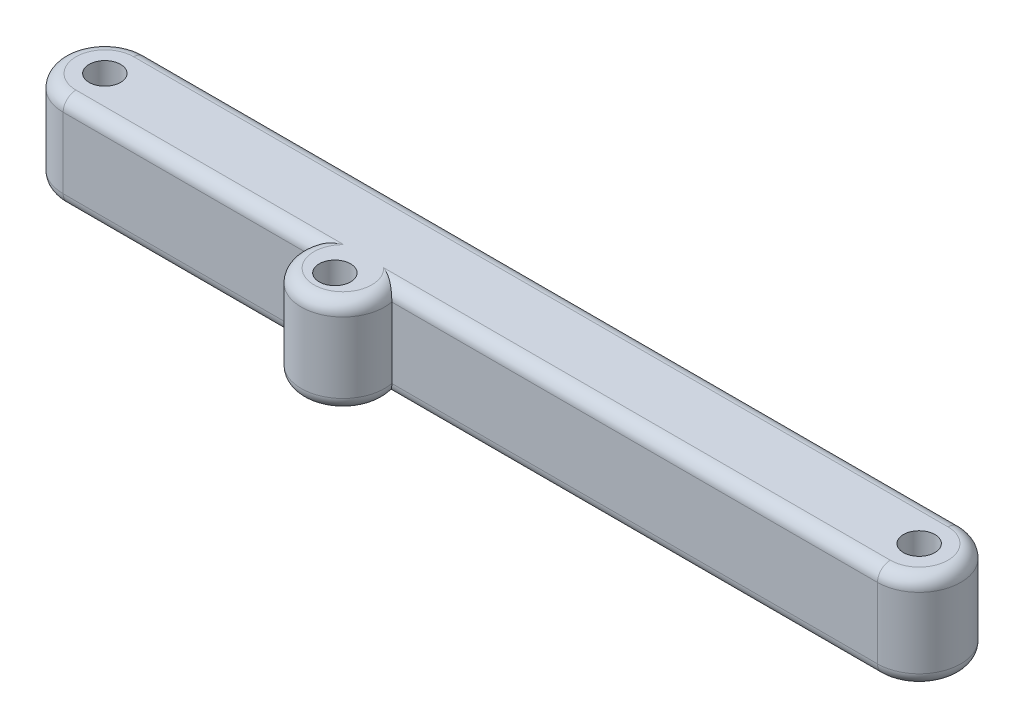
from build123d import *

# Parameters (mm, degrees)
SKETCH1_R           = 3.1115
BOSS_EXTRUDE1_DEPTH = 19.05
SKETCH2_R           = 8.255
SKETCH2_R_2         = 3.1115
BOSS_EXTRUDE2_DEPTH = 19.05
FILLET1_R           = 2.54


with BuildPart() as part:
    # Sketch1 → Boss-Extrude1 (new body)
    with BuildSketch(Plane(origin=(0, 0, 0), x_dir=(1, 0, 0), z_dir=(0, 1, 0))):
        with BuildLine():
            Line((-80.645, -8.255), (80.645, -8.255))
            ThreePointArc((80.645, -8.255), (88.9, 0), (80.645, 8.255))
            Line((80.645, 8.255), (-80.645, 8.255))
            ThreePointArc((-80.645, 8.255), (-88.9, 0), (-80.645, -8.255))
        make_face()
        with Locations((-80.645, 0)):
            Circle(SKETCH1_R, mode=Mode.SUBTRACT)
        with Locations((80.645, 0)):
            Circle(SKETCH1_R, mode=Mode.SUBTRACT)
    extrude(amount=BOSS_EXTRUDE1_DEPTH)

    # Sketch2 → Boss-Extrude2 (add)
    with BuildSketch(Plane(origin=(0, 19.05, 0), x_dir=(1, 0, 0), z_dir=(0, 1, 0))):
        with Locations((-23.650230322, -9.8425)):
            Circle(SKETCH2_R)
        with Locations((-23.650230322, -11.43)):
            Circle(SKETCH2_R_2, mode=Mode.SUBTRACT)
    extrude(amount=-BOSS_EXTRUDE2_DEPTH)

    # Fillet1
    fillet1_edges = [part.edges().sort_by_distance(p)[0] for p in [
        (88.9, 19.05, 0),
        (0, 19.05, -8.255),
        (32.547843725, 0, 8.255),
        (32.547843725, 19.05, 8.255),
        (-23.650230322, 19.05, 18.0975),
        (-23.650230322, 0, 18.0975),
        (-88.9, 19.05, 0),
        (0, 0, -8.255),
        (88.9, 0, 0),
        (-56.198074047, 0, 8.255),
        (-88.9, 0, 0),
        (-56.198074047, 19.05, 8.255),
    ]]
    fillet(fillet1_edges, radius=FILLET1_R)


solid = part.part
